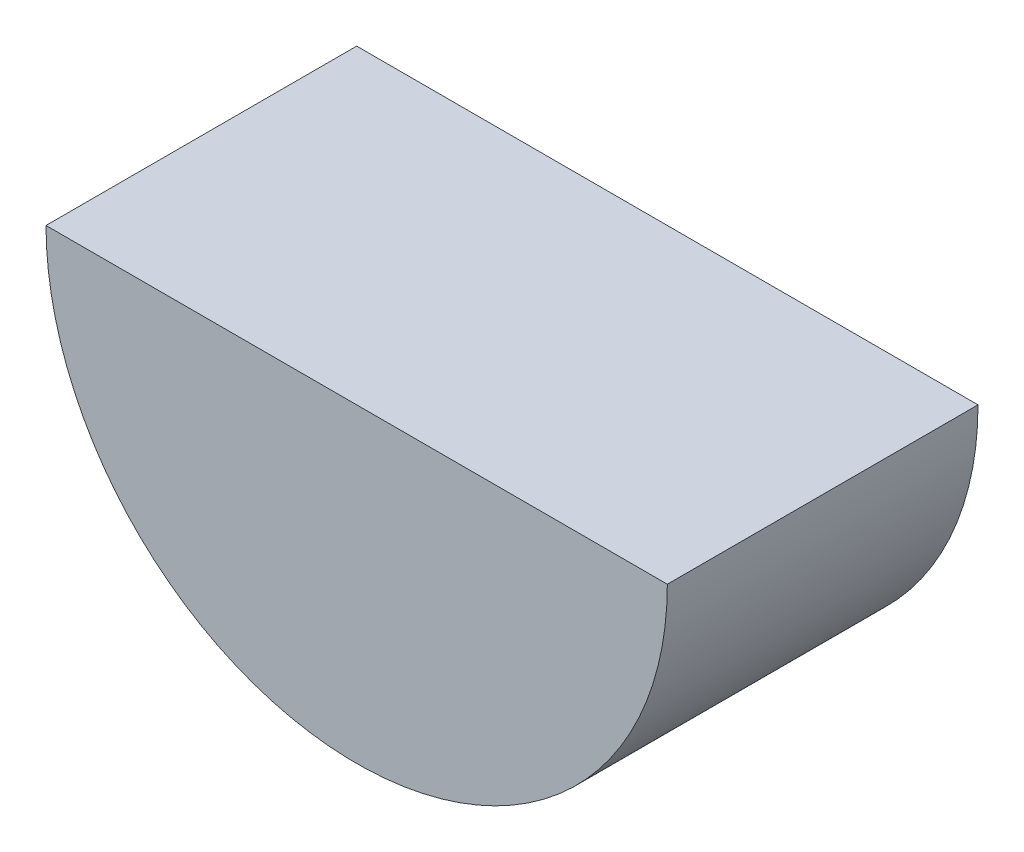
from build123d import *

# Parameters (mm, degrees)
BOSS_EXTRUDE1_DEPTH = 7.5


with BuildPart() as part:
    # Sketch2 → Boss-Extrude1 (new body, symmetric)
    with BuildSketch(Plane.XY):
        with BuildLine():
            Line((-15, 0), (15, 0))
            ThreePointArc((15, 0), (0, -15), (-15, 0))
        make_face()
    extrude(amount=BOSS_EXTRUDE1_DEPTH, both=True)


solid = part.part
